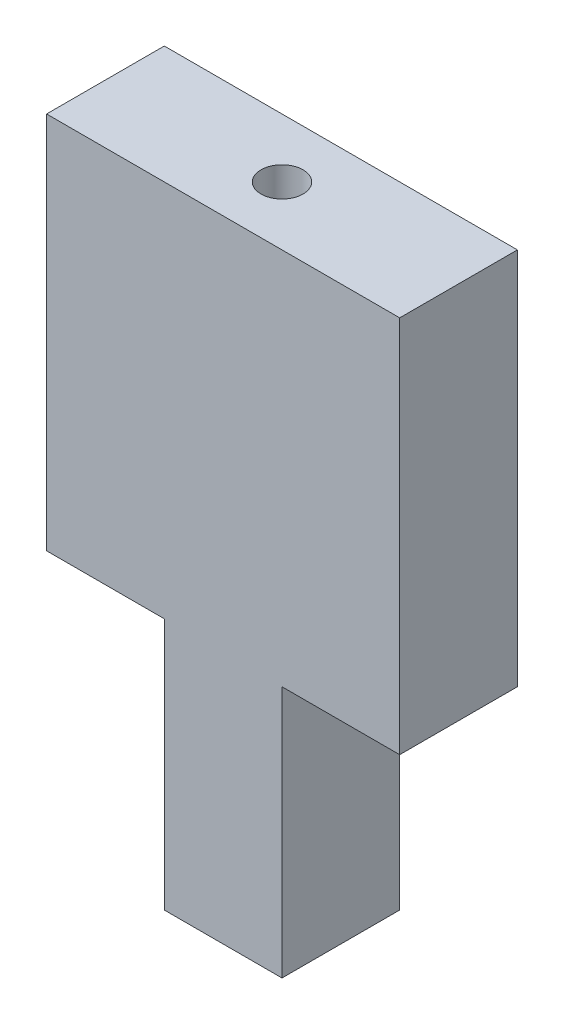
from build123d import *

# Parameters (mm, degrees)
SKETCH1_W           = 14
SKETCH1_H           = 14
BOSS_EXTRUDE1_DEPTH = 75
SKETCH2_R           = 2.5
CUT_EXTRUDE1_DEPTH  = 30
SKETCH3_W           = 14
SKETCH3_H           = 45
BOSS_EXTRUDE2_DEPTH = 14
SKETCH4_W           = 14
SKETCH4_H           = 45
BOSS_EXTRUDE3_DEPTH = 14


with BuildPart() as part:
    # Sketch1 → Boss-Extrude1 (new body)
    with BuildSketch(Plane(origin=(0, 0, 0), x_dir=(1, 0, 0), z_dir=(0, 1, 0))):
        Rectangle(SKETCH1_W, SKETCH1_H)
    extrude(amount=BOSS_EXTRUDE1_DEPTH)

    # Sketch2 → Cut-Extrude1 (cut)
    with BuildSketch(Plane(origin=(0, 75, 0), x_dir=(1, 0, 0), z_dir=(0, 1, 0))):
        Circle(SKETCH2_R)
    extrude(amount=-CUT_EXTRUDE1_DEPTH, mode=Mode.SUBTRACT)

    # Sketch3 → Boss-Extrude2 (add)
    with BuildSketch(Plane(origin=(7, 0, 0), x_dir=(0, 0, -1), z_dir=(1, 0, 0))):
        with Locations((0, 52.5)):
            Rectangle(SKETCH3_W, SKETCH3_H)
    extrude(amount=BOSS_EXTRUDE2_DEPTH)

    # Sketch4 → Boss-Extrude3 (add)
    with BuildSketch(Plane.ZY.offset(7)):
        with Locations((0, 52.5)):
            Rectangle(SKETCH4_W, SKETCH4_H)
    extrude(amount=BOSS_EXTRUDE3_DEPTH)


solid = part.part
